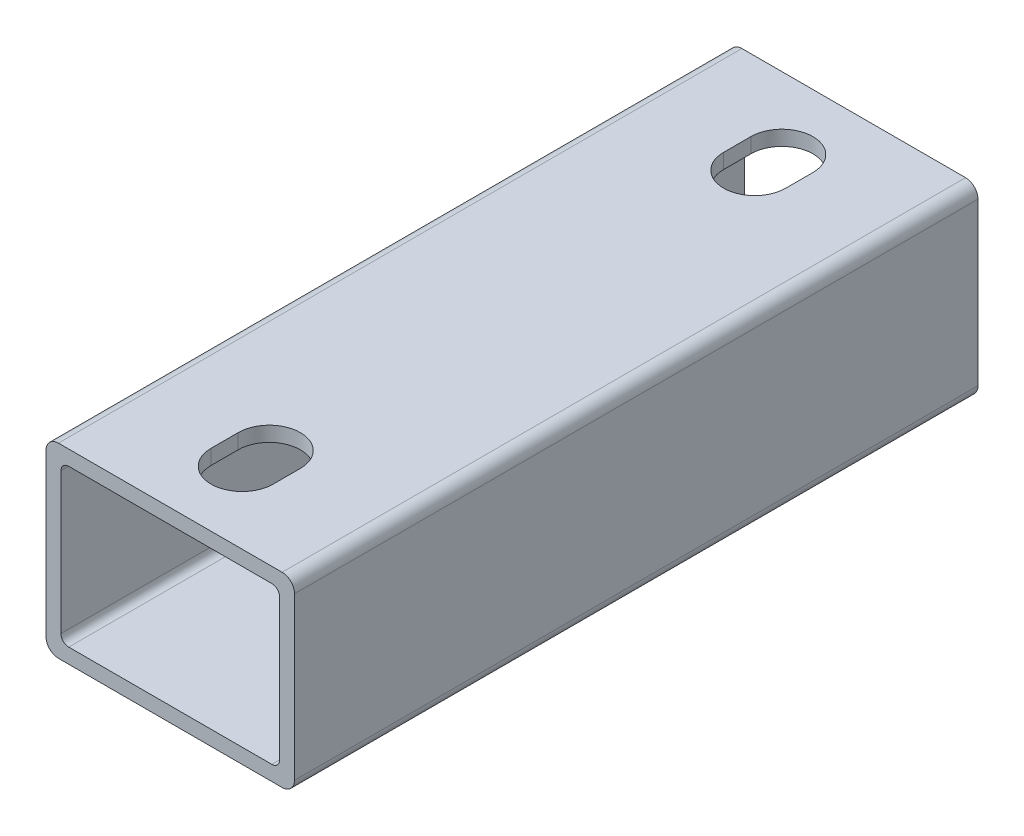
from build123d import *

# Parameters (mm, degrees)
BOSS_EXTRUDE1_DEPTH = 139.7
CUT_EXTRUDE1_DEPTH  = 3.048


with BuildPart() as part:
    # Sketch4 → Boss-Extrude1 (new body)
    with BuildSketch(Plane.XY):
        with BuildLine():
            Line((25.4, -16.51), (25.4, 16.51))
            ThreePointArc((25.4, 16.51), (24.656051224, 18.306051224), (22.86, 19.05))
            Line((22.86, 19.05), (-22.86, 19.05))
            ThreePointArc((-22.86, 19.05), (-24.656051224, 18.306051224), (-25.4, 16.51))
            Line((-25.4, 16.51), (-25.4, -16.51))
            ThreePointArc((-25.4, -16.51), (-24.656051224, -18.306051224), (-22.86, -19.05))
            Line((-22.86, -19.05), (22.86, -19.05))
            ThreePointArc((22.86, -19.05), (24.656051224, -18.306051224), (25.4, -16.51))
        make_face()
        with BuildLine():
            Line((22.352, 14.4018), (22.352, -14.4018))
            ThreePointArc((22.352, -14.4018), (21.883312271, -15.533312271), (20.7518, -16.002))
            Line((20.7518, -16.002), (-20.7518, -16.002))
            ThreePointArc((-20.7518, -16.002), (-21.883312271, -15.533312271), (-22.352, -14.4018))
            Line((-22.352, -14.4018), (-22.352, 14.4018))
            ThreePointArc((-22.352, 14.4018), (-21.883312271, 15.533312271), (-20.7518, 16.002))
            Line((-20.7518, 16.002), (20.7518, 16.002))
            ThreePointArc((20.7518, 16.002), (21.883312271, 15.533312271), (22.352, 14.4018))
        make_face(mode=Mode.SUBTRACT)
    extrude(amount=BOSS_EXTRUDE1_DEPTH)

    # Sketch7 → Cut-Extrude1 (cut)
    with BuildSketch(Plane(origin=(0, 19.05, 0), x_dir=(1, 0, 0), z_dir=(0, 1, 0))):
        with BuildLine():
            Line((-6.35, -20.240625), (-6.35, -14.684375))
            ThreePointArc((-6.35, -14.684375), (0, -8.334375), (6.35, -14.684375))
            Line((6.35, -14.684375), (6.35, -20.240625))
            ThreePointArc((6.35, -20.240625), (0, -26.590625), (-6.35, -20.240625))
        make_face()
        with BuildLine():
            Line((-6.35, -125.015625), (-6.35, -119.459375))
            ThreePointArc((-6.35, -119.459375), (0, -113.109375), (6.35, -119.459375))
            Line((6.35, -119.459375), (6.35, -125.015625))
            ThreePointArc((6.35, -125.015625), (0, -131.365625), (-6.35, -125.015625))
        make_face()
    extrude(amount=-CUT_EXTRUDE1_DEPTH, mode=Mode.SUBTRACT)


solid = part.part
